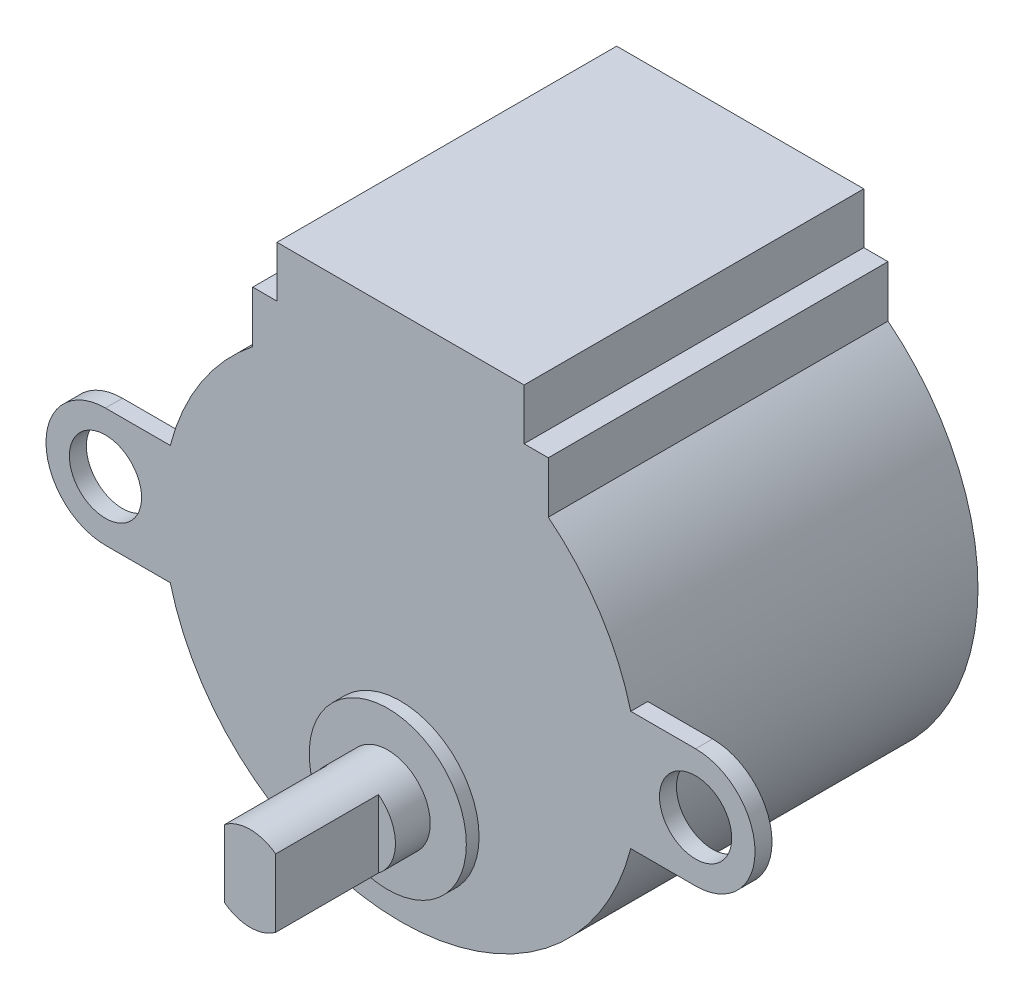
from build123d import *
from build123d.topology import SkipClean

# Parameters (mm, degrees)
EXTRUDE_1_DEPTH = 20
SKETCH_2_R      = 2.125
EXTRUDE_2_DEPTH = 1
SKETCH_3_R      = 4.625
EXTRUDE_3_DEPTH = 0.75
SKETCH_4_R      = 2.5
EXTRUDE_4_DEPTH = 2.05
EXTRUDE_5_DEPTH = 6.05


with BuildPart() as part:
    # Sketch 1 → Extrude 1 (new body)
    with BuildSketch(Plane.XY):
        with BuildLine():
            Line((-7.275, 17), (7.275, 17))
            Line((7.275, 17), (7.275, 14))
            Line((7.275, 14), (8.7, 14))
            Line((8.7, 14), (8.7, 10.968591523))
            ThreePointArc((8.7, 10.968591523), (0, -14), (-8.7, 10.968591523))
            Line((-8.7, 10.968591523), (-8.7, 14))
            Line((-8.7, 14), (-7.275, 14))
            Line((-7.275, 14), (-7.275, 17))
        make_face()
    extrude(amount=EXTRUDE_1_DEPTH)

    # Sketch 2 → Extrude 2 (add)
    with BuildSketch(Plane.XY.offset(20)):
        with BuildLine():
            Line((-17.372355088, 3.5), (17.372355088, 3.5))
            ThreePointArc((17.372355088, 3.5), (20.872355088, 0), (17.372355088, -3.5))
            Line((17.372355088, -3.5), (-17.372355088, -3.5))
            ThreePointArc((-17.372355088, -3.5), (-20.872355088, 0), (-17.372355088, 3.5))
        make_face()
        with Locations((-17.372355088, 0)):
            Circle(SKETCH_2_R, mode=Mode.SUBTRACT)
        with Locations(Location((17.372355088, 0, 0), (0, 0, 180))):
            Circle(SKETCH_2_R, mode=Mode.SUBTRACT)
    extrude(amount=-EXTRUDE_2_DEPTH)

    # Sketch 3 → Extrude 3 (add)
    with BuildSketch(Plane.XY.offset(20)):
        with Locations((0, -7.375)):
            Circle(SKETCH_3_R)
    extrude(amount=EXTRUDE_3_DEPTH)

    # Sketch 4 → Extrude 4 (add)
    with BuildSketch(Plane.XY.offset(20.75)):
        with Locations((0, -7.375)):
            Circle(SKETCH_4_R)
    extrude(amount=EXTRUDE_4_DEPTH)

    # Sketch 5 → Extrude 5 (add)
    with SkipClean():  # the faces are left unmerged after this step: merging them gives an invalid solid
        with BuildSketch(Plane.XY.offset(22.8)):
            with BuildLine():
                Line((-1.5, -9.375), (-1.5, -5.375))
                ThreePointArc((-1.5, -5.375), (0, -4.875), (1.5, -5.375))
                Line((1.5, -5.375), (1.5, -9.375))
                ThreePointArc((1.5, -9.375), (0, -9.875), (-1.5, -9.375))
            make_face()
        extrude(amount=EXTRUDE_5_DEPTH)


solid = part.part
